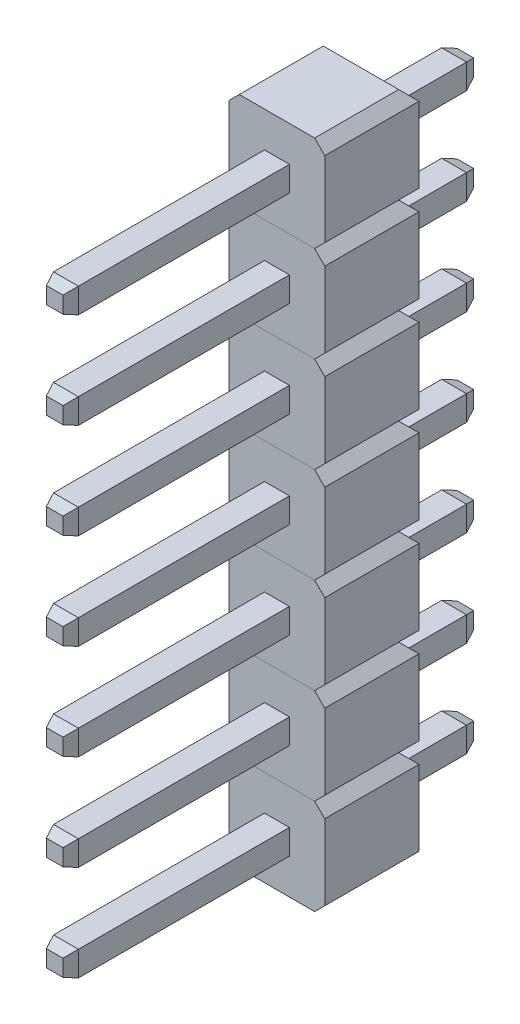
from build123d import *

# Parameters (mm, degrees)
BOSS_EXTRUDE1_DEPTH      = 2.5
CUT_EXTRUDE1_DEPTH       = 2.27
CUT_EXTRUDE1_DEPTH_BACK  = 2.27
SKETCH2_W                = 0.66
SKETCH2_H                = 0.66
BOSS_EXTRUDE2_DEPTH      = 8.4
BOSS_EXTRUDE2_DEPTH_BACK = 2.5
CHAMFER1_SIZE            = 0.3
CHAMFER1_SIZE2           = 0.10919107
CHAMFER1_PART_2_SIZE     = 0.3
CHAMFER1_PART_2_SIZE2    = 0.10919107
CHAMFER1_PART_3_SIZE     = 0.3
CHAMFER1_PART_3_SIZE2    = 0.10919107
CHAMFER1_PART_4_SIZE     = 0.3
CHAMFER1_PART_4_SIZE2    = 0.10919107
CHAMFER1_PART_5_SIZE     = 0.3
CHAMFER1_PART_5_SIZE2    = 0.10919107
CHAMFER1_PART_6_SIZE     = 0.3
CHAMFER1_PART_6_SIZE2    = 0.10919107
CHAMFER1_PART_7_SIZE     = 0.3
CHAMFER1_PART_7_SIZE2    = 0.10919107
CHAMFER1_PART_8_SIZE     = 0.3
CHAMFER1_PART_8_SIZE2    = 0.10919107
LPATTERN1_COUNT          = 7
LPATTERN1_PITCH          = 2.54


with BuildPart() as part:
    # Sketch1 → Boss-Extrude1 (new body)
    with BuildSketch(Plane.XY):
        Polygon((-1.27, 1), (-1, 1.27), (1, 1.27), (1.27, 1), (1.27, -1), (1, -1.27), (-1, -1.27), (-1.27, -1), align=None)
    extrude(amount=BOSS_EXTRUDE1_DEPTH)

    # Sketch4 → Cut-Extrude1 (cut, two sides)
    with BuildSketch(Plane(origin=(0, 0, 0), x_dir=(1, 0, 0), z_dir=(0, 1, 0))) as cut_extrude1_sk:
        Polygon((-1.27, 0), (1.27, 0), (1, -0.27), (-1, -0.27), align=None)
    extrude(amount=CUT_EXTRUDE1_DEPTH, mode=Mode.SUBTRACT)
    extrude(cut_extrude1_sk.sketch, amount=-CUT_EXTRUDE1_DEPTH_BACK, mode=Mode.SUBTRACT)

    # Sketch2 → Boss-Extrude2 (add, two sides)
    with BuildSketch(Plane.XY) as boss_extrude2_sk:
        Rectangle(SKETCH2_W, SKETCH2_H)
    extrude(amount=BOSS_EXTRUDE2_DEPTH)
    extrude(boss_extrude2_sk.sketch, amount=-BOSS_EXTRUDE2_DEPTH_BACK)

    # Chamfer1
    chamfer1_edges = [part.edges().sort_by_distance(p)[0] for p in [
        (0.33, 0, -2.5),
    ]]
    chamfer1_side = [part.faces().sort_by_distance(p)[0] for p in [
        (0.33, 0, -1.115),
    ]]
    chamfer(chamfer1_edges, length=CHAMFER1_SIZE, length2=CHAMFER1_SIZE2, reference=chamfer1_side[0])

    # Chamfer1 part 2
    chamfer1_part_2_edges = [part.edges().sort_by_distance(p)[0] for p in [
        (0, 0.33, -2.5),
    ]]
    chamfer1_part_2_side = [part.faces().sort_by_distance(p)[0] for p in [
        (0, 0.33, -1.115),
    ]]
    chamfer(chamfer1_part_2_edges, length=CHAMFER1_PART_2_SIZE, length2=CHAMFER1_PART_2_SIZE2, reference=chamfer1_part_2_side[0])

    # Chamfer1 part 3
    chamfer1_part_3_edges = [part.edges().sort_by_distance(p)[0] for p in [
        (-0.33, 0, -2.5),
    ]]
    chamfer1_part_3_side = [part.faces().sort_by_distance(p)[0] for p in [
        (-0.33, 0, -1.115),
    ]]
    chamfer(chamfer1_part_3_edges, length=CHAMFER1_PART_3_SIZE, length2=CHAMFER1_PART_3_SIZE2, reference=chamfer1_part_3_side[0])

    # Chamfer1 part 4
    chamfer1_part_4_edges = [part.edges().sort_by_distance(p)[0] for p in [
        (0, -0.33, -2.5),
    ]]
    chamfer1_part_4_side = [part.faces().sort_by_distance(p)[0] for p in [
        (0, -0.33, -1.115),
    ]]
    chamfer(chamfer1_part_4_edges, length=CHAMFER1_PART_4_SIZE, length2=CHAMFER1_PART_4_SIZE2, reference=chamfer1_part_4_side[0])

    # Chamfer1 part 5
    chamfer1_part_5_edges = [part.edges().sort_by_distance(p)[0] for p in [
        (0.33, 0, 8.4),
    ]]
    chamfer1_part_5_side = [part.faces().sort_by_distance(p)[0] for p in [
        (0.33, 0, 5.45),
    ]]
    chamfer(chamfer1_part_5_edges, length=CHAMFER1_PART_5_SIZE, length2=CHAMFER1_PART_5_SIZE2, reference=chamfer1_part_5_side[0])

    # Chamfer1 part 6
    chamfer1_part_6_edges = [part.edges().sort_by_distance(p)[0] for p in [
        (0, 0.33, 8.4),
    ]]
    chamfer1_part_6_side = [part.faces().sort_by_distance(p)[0] for p in [
        (0, 0.33, 5.45),
    ]]
    chamfer(chamfer1_part_6_edges, length=CHAMFER1_PART_6_SIZE, length2=CHAMFER1_PART_6_SIZE2, reference=chamfer1_part_6_side[0])

    # Chamfer1 part 7
    chamfer1_part_7_edges = [part.edges().sort_by_distance(p)[0] for p in [
        (-0.33, 0, 8.4),
    ]]
    chamfer1_part_7_side = [part.faces().sort_by_distance(p)[0] for p in [
        (-0.33, 0, 5.45),
    ]]
    chamfer(chamfer1_part_7_edges, length=CHAMFER1_PART_7_SIZE, length2=CHAMFER1_PART_7_SIZE2, reference=chamfer1_part_7_side[0])

    # Chamfer1 part 8
    chamfer1_part_8_edges = [part.edges().sort_by_distance(p)[0] for p in [
        (0, -0.33, 8.4),
    ]]
    chamfer1_part_8_side = [part.faces().sort_by_distance(p)[0] for p in [
        (0, -0.33, 5.45),
    ]]
    chamfer(chamfer1_part_8_edges, length=CHAMFER1_PART_8_SIZE, length2=CHAMFER1_PART_8_SIZE2, reference=chamfer1_part_8_side[0])


with BuildPart() as lpattern1_1:
    # LPattern1: pattern copy
    add(part.part.moved(Location(Vector(0, 1, 0) * (1 * LPATTERN1_PITCH))))


with BuildPart() as lpattern1_2:
    # LPattern1: pattern copy
    add(part.part.moved(Location(Vector(0, 1, 0) * (2 * LPATTERN1_PITCH))))


with BuildPart() as lpattern1_3:
    # LPattern1: pattern copy
    add(part.part.moved(Location(Vector(0, 1, 0) * (3 * LPATTERN1_PITCH))))


with BuildPart() as lpattern1_4:
    # LPattern1: pattern copy
    add(part.part.moved(Location(Vector(0, 1, 0) * (4 * LPATTERN1_PITCH))))


with BuildPart() as lpattern1_5:
    # LPattern1: pattern copy
    add(part.part.moved(Location(Vector(0, 1, 0) * (5 * LPATTERN1_PITCH))))


with BuildPart() as lpattern1_6:
    # LPattern1: pattern copy
    add(part.part.moved(Location(Vector(0, 1, 0) * (6 * LPATTERN1_PITCH))))


solid = Compound([part.part, lpattern1_1.part, lpattern1_2.part, lpattern1_3.part, lpattern1_4.part, lpattern1_5.part, lpattern1_6.part])
